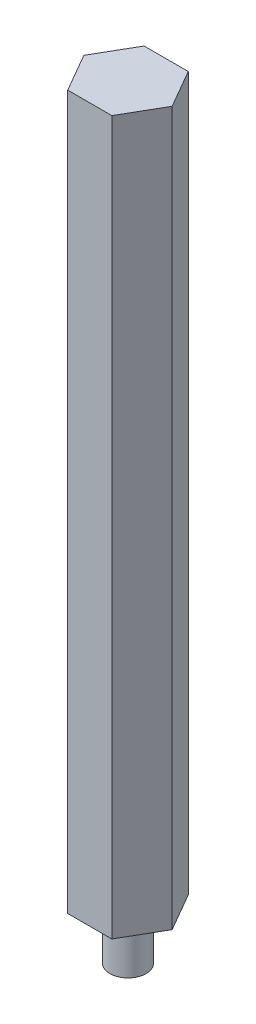
from build123d import *

# Parameters (mm, degrees)
BOSS_EXTRUDE1_DEPTH = 127
SKETCH3_R           = 18.31161494
SKETCH3_R_2         = 3
CUT_EXTRUDE1_DEPTH  = 8.5


with BuildPart() as part:
    # Sketch1 → Boss-Extrude1 (new body)
    with BuildSketch(Plane(origin=(0, 0, 0), x_dir=(1, 0, 0), z_dir=(0, 1, 0))):
        Polygon((7.332348419, 0), (3.666174209, 6.35), (-3.666174209, 6.35), (-7.332348419, 0), (-3.666174209, -6.35), (3.666174209, -6.35), align=None)
    extrude(amount=BOSS_EXTRUDE1_DEPTH)

    # Sketch3 → Cut-Extrude1 (cut)
    with BuildSketch(Plane.XZ):
        Circle(SKETCH3_R)
        Circle(SKETCH3_R_2, mode=Mode.SUBTRACT)
    extrude(amount=-CUT_EXTRUDE1_DEPTH, mode=Mode.SUBTRACT)


solid = part.part
